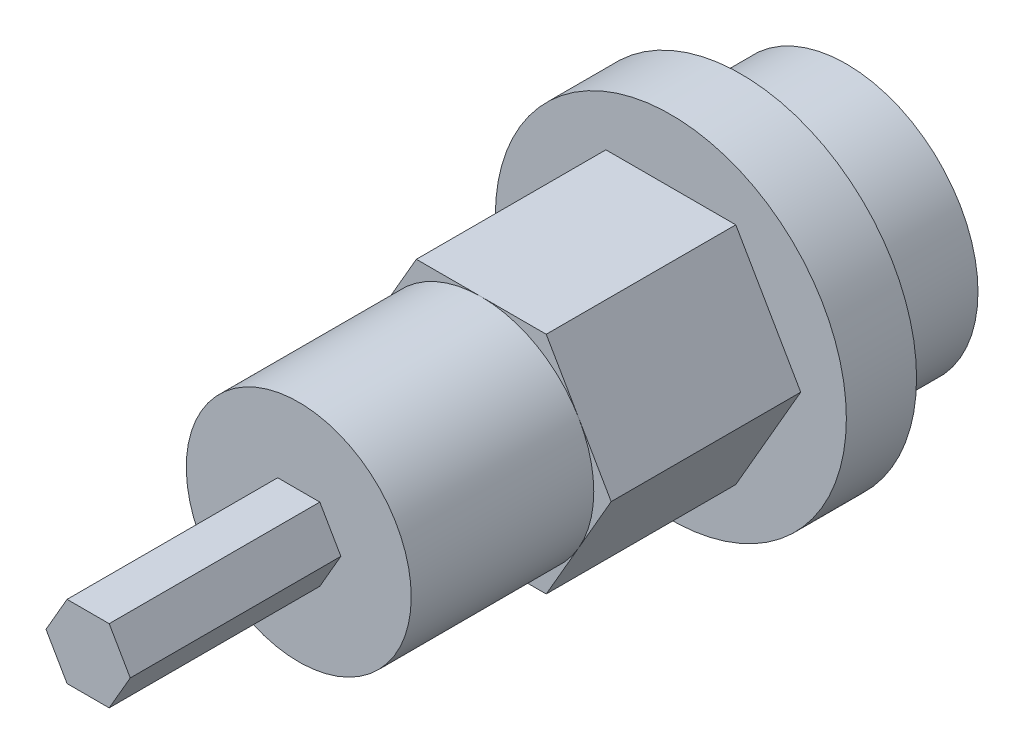
from build123d import *

# Parameters (mm, degrees)
SKETCH1_R           = 3.75
BOSS_EXTRUDE1_DEPTH = 3
SKETCH2_R           = 5
BOSS_EXTRUDE2_DEPTH = 2
BOSS_EXTRUDE3_DEPTH = 5.4
SKETCH4_R           = 3.204293994
BOSS_EXTRUDE4_DEPTH = 5.2
BOSS_EXTRUDE5_DEPTH = 6


with BuildPart() as part:
    # Sketch1 → Boss-Extrude1 (new body)
    with BuildSketch(Plane.XY):
        Circle(SKETCH1_R)
    extrude(amount=BOSS_EXTRUDE1_DEPTH)

    # Sketch2 → Boss-Extrude2 (add)
    with BuildSketch(Plane.XY.offset(3)):
        Circle(SKETCH2_R)
    extrude(amount=BOSS_EXTRUDE2_DEPTH)

    # Sketch3 → Boss-Extrude3 (add)
    with BuildSketch(Plane.XY.offset(5)):
        Polygon((3.7, 0), (1.85, 3.204293994), (-1.85, 3.204293994), (-3.7, 0), (-1.85, -3.204293994), (1.85, -3.204293994), align=None)
    extrude(amount=BOSS_EXTRUDE3_DEPTH)

    # Sketch4 → Boss-Extrude4 (add)
    with BuildSketch(Plane.XY.offset(10.4)):
        Circle(SKETCH4_R)
    extrude(amount=BOSS_EXTRUDE4_DEPTH)

    # Sketch5 → Boss-Extrude5 (add)
    with BuildSketch(Plane.XY.offset(15.6)):
        Polygon((1.2, 0), (0.6, 1.039230485), (-0.6, 1.039230485), (-1.2, 0), (-0.6, -1.039230485), (0.6, -1.039230485), align=None)
    extrude(amount=BOSS_EXTRUDE5_DEPTH)


solid = part.part
